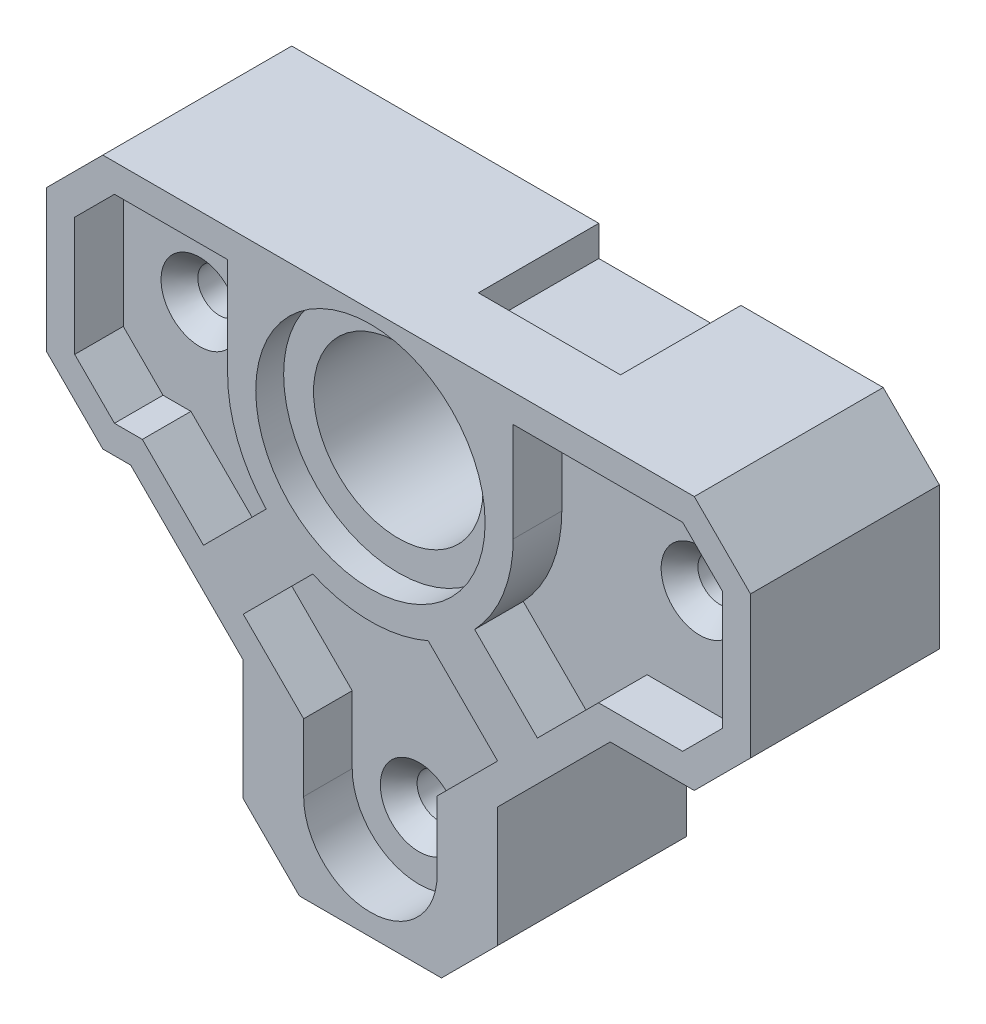
from build123d import *

# Parameters (mm, degrees)
BOSS_EXTRUDE1_DEPTH                           = 10.668
CSK_FOR_2_FLAT_HEAD_MACHINE_SCREW1_AT_2_COUNT = 2
CSK_FOR_2_FLAT_HEAD_MACHINE_SCREW1_AT_2_PITCH = 28.241625
CSK_FOR_2_FLAT_HEAD_MACHINE_SCREW1_AT_3_COUNT = 2
CSK_FOR_2_FLAT_HEAD_MACHINE_SCREW1_AT_3_PITCH = 24.379834317
SKETCH4_R                                     = 6.477
CUT_EXTRUDE1_DEPTH                            = 1.5748
SKETCH5_R                                     = 4.7879
CUT_EXTRUDE2_DEPTH                            = 11.668
SKETCH6_W                                     = 8.0264
SKETCH6_H                                     = 10.033
CUT_EXTRUDE3_DEPTH                            = 5.08
DRAFT2_ANGLE                                  = 45
CHAMFER1_SIZE                                 = 3.175
CHAMFER2_SIZE                                 = 6.35
CUT_EXTRUDE4_DEPTH                            = 2.7432


with BuildPart() as part:
    # Sketch1 → Boss-Extrude1 (new body)
    with BuildSketch(Plane.XY):
        Polygon((21.463, 7.1882), (-18.288, 7.1882), (-18.288, -7.1882), (-7.1882, -7.1882), (-7.1882, -23.495), (7.1882, -23.495), (7.1882, -7.1882), (21.463, -7.1882), align=None)
    extrude(amount=BOSS_EXTRUDE1_DEPTH)

    # Sketch3 → CSK for #2 Flat Head Machine Screw1 (revolve, cut)
    with BuildSketch(Plane(origin=(15.859125, 0, 10.668), x_dir=(0, -1, 0), z_dir=(1, 0, 0))):
        Polygon((0, 0), (0, 10.668), (1.2192, 10.668), (1.2192, 3.853535587), (2.1844, 2.7432), (2.1844, 0), align=None)
    csk_for_2_flat_head_machine_screw1 = revolve(axis=Axis((15.859125, 0, 17.018), (0, 0, -1)), mode=Mode.SUBTRACT)

    # CSK for #2 Flat Head Machine Screw1 at 2: CSK for #2 Flat Head Machine Screw1 ×2
    with Locations(*[(-i * CSK_FOR_2_FLAT_HEAD_MACHINE_SCREW1_AT_2_PITCH, 0, 0) for i in range(1, CSK_FOR_2_FLAT_HEAD_MACHINE_SCREW1_AT_2_COUNT)]):
        add(csk_for_2_flat_head_machine_screw1, mode=Mode.SUBTRACT)

    # CSK for #2 Flat Head Machine Screw1 at 3: CSK for #2 Flat Head Machine Screw1 ×2
    with Locations(*[Vector(-0.650501755, -0.759504751, 0) * (i * CSK_FOR_2_FLAT_HEAD_MACHINE_SCREW1_AT_3_PITCH) for i in range(1, CSK_FOR_2_FLAT_HEAD_MACHINE_SCREW1_AT_3_COUNT)]):
        add(csk_for_2_flat_head_machine_screw1, mode=Mode.SUBTRACT)

    # Sketch4 → Cut-Extrude1 (cut)
    with BuildSketch(Plane.XY.offset(10.668)):
        Circle(SKETCH4_R)
    extrude(amount=-CUT_EXTRUDE1_DEPTH, mode=Mode.SUBTRACT)

    # Sketch5 → Cut-Extrude2 (cut, through all)
    with BuildSketch(Plane.XY.offset(10.668)):
        Circle(SKETCH5_R)
    extrude(amount=-CUT_EXTRUDE2_DEPTH, mode=Mode.SUBTRACT)

    # Sketch6 → Cut-Extrude3 (cut)
    with BuildSketch(Plane(origin=(0, 0, 0), x_dir=(-1, 0, 0), z_dir=(0, 0, -1))):
        with Locations((-6.24205, 10.483214746)):
            Rectangle(SKETCH6_W, SKETCH6_H)
    extrude(amount=-CUT_EXTRUDE3_DEPTH, mode=Mode.SUBTRACT)

    # Draft2
    draft2_faces = [part.faces().sort_by_distance(p)[0] for p in [
        (6.24205, 6.327457373, 5.08),
    ]]
    draft(draft2_faces, Plane(origin=(10.25525, 5.466714746, 5.08), x_dir=(1, 0, 0), z_dir=(0, 1, 0)), DRAFT2_ANGLE)

    # Chamfer1
    chamfer1_edges = [part.edges().sort_by_distance(p)[0] for p in [
        (21.463, -7.1882, 5.334),
        (7.1882, -23.495, 5.334),
        (-7.1882, -23.495, 5.334),
        (-18.288, -7.1882, 5.334),
        (-18.288, 7.1882, 5.334),
        (21.463, 7.1882, 5.334),
    ]]
    chamfer(chamfer1_edges, length=CHAMFER1_SIZE)

    # Chamfer2
    chamfer2_edges = [part.edges().sort_by_distance(p)[0] for p in [
        (7.1882, -7.1882, 5.334),
        (-7.1882, -7.1882, 5.334),
    ]]
    chamfer(chamfer2_edges, length=CHAMFER2_SIZE)

    # Sketch7 → Cut-Extrude4 (cut)
    with BuildSketch(Plane.XY.offset(10.668)):
        with BuildLine():
            Line((3.7719, -14.70943597), (7.183135951, -11.298200019))
            Line((7.183135951, -11.298200019), (3.260798724, -7.375862792))
            ThreePointArc((3.260798724, -7.375862792), (0, -8.0645), (-3.260798724, -7.375862792))
            Line((-3.260798724, -7.375862792), (-7.183135951, -11.298200019))
            Line((-7.183135951, -11.298200019), (-3.7719, -14.70943597))
            Line((-3.7719, -14.70943597), (-3.7719, -18.5166))
            ThreePointArc((-3.7719, -18.5166), (0, -22.2885), (3.7719, -18.5166))
            Line((3.7719, -18.5166), (3.7719, -14.70943597))
        make_face()
        with BuildLine():
            Line((12.88063597, -5.6007), (17.63043597, -5.6007))
            Line((17.63043597, -5.6007), (19.8755, -3.35563597))
            Line((19.8755, -3.35563597), (19.8755, 3.35563597))
            Line((19.8755, 3.35563597), (17.63043597, 5.6007))
            Line((17.63043597, 5.6007), (8.0645, 5.6007))
            Line((8.0645, 5.6007), (8.0645, 0))
            ThreePointArc((8.0645, 0), (7.500371575, -2.963205441), (5.886910197, -5.511846205))
            Line((5.886910197, -5.511846205), (9.428199981, -9.053135989))
            Line((9.428199981, -9.053135989), (12.88063597, -5.6007))
        make_face()
        with BuildLine():
            Line((-14.45543597, 5.6007), (-16.7005, 3.35563597))
            Line((-16.7005, 3.35563597), (-16.7005, -3.35563597))
            Line((-16.7005, -3.35563597), (-14.45543597, -5.6007))
            Line((-14.45543597, -5.6007), (-12.88063597, -5.6007))
            Line((-12.88063597, -5.6007), (-9.428199981, -9.053135989))
            Line((-9.428199981, -9.053135989), (-5.886910197, -5.511846205))
            ThreePointArc((-5.886910197, -5.511846205), (-7.500371575, -2.963205441), (-8.0645, 0))
            Line((-8.0645, 0), (-8.0645, 5.6007))
            Line((-8.0645, 5.6007), (-14.45543597, 5.6007))
        make_face()
    extrude(amount=-CUT_EXTRUDE4_DEPTH, mode=Mode.SUBTRACT)


solid = part.part
